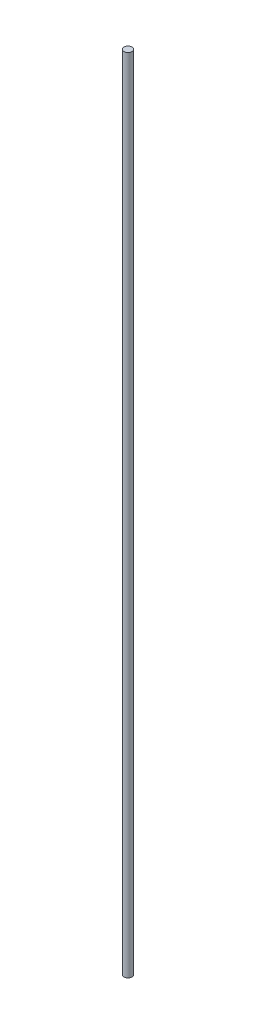
from build123d import *

# Parameters (mm, degrees)
SKETCH1_R           = 4
BOSS_EXTRUDE1_DEPTH = 800


with BuildPart() as part:
    # Sketch1 → Boss-Extrude1 (new body)
    with BuildSketch(Plane(origin=(0, 0, 0), x_dir=(1, 0, 0), z_dir=(0, 1, 0))):
        with Locations((-6.877192982, 1.438596491)):
            Circle(SKETCH1_R)
    extrude(amount=BOSS_EXTRUDE1_DEPTH)


solid = part.part
